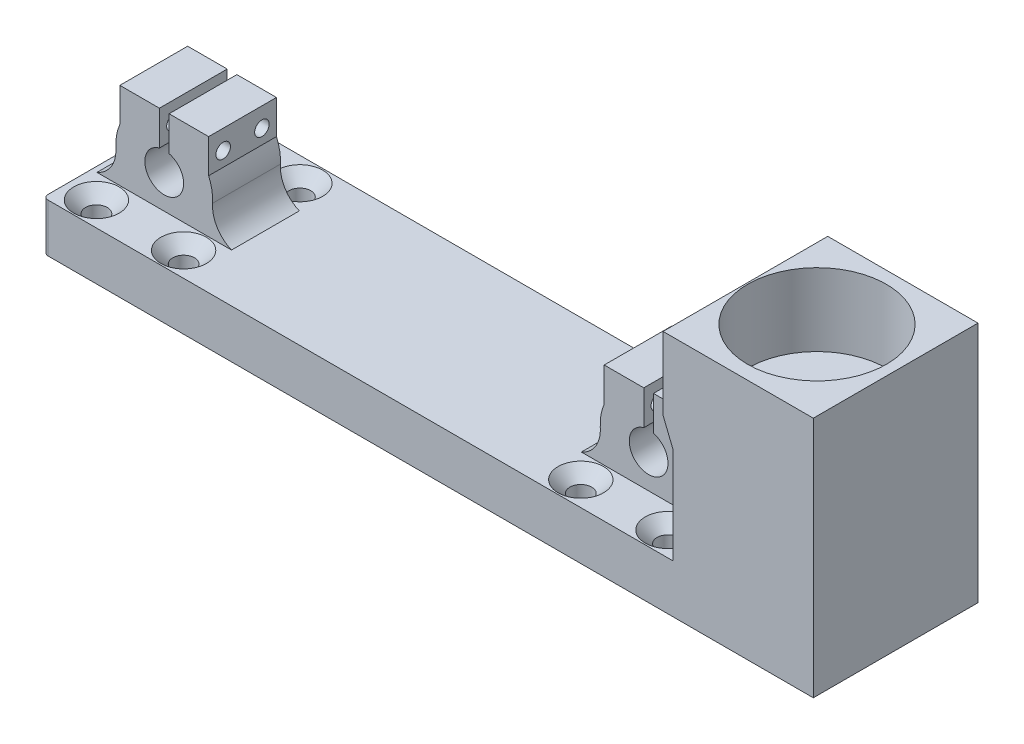
from build123d import *

# Parameters (mm, degrees)
SKETCH2_W                                       = 35
SKETCH2_H                                       = 34
SKETCH2_W_2                                     = 30
SKETCH2_R                                       = 2
BOSS_EXTRUDE1_DEPTH                             = 10
FILLET1_R                                       = 1
CSK_FOR_M4_FLAT_HEAD_MACHINE_SCREW1_D           = 4.5
CSK_FOR_M4_FLAT_HEAD_MACHINE_SCREW1_DEPTH       = 10
CSK_FOR_M4_FLAT_HEAD_MACHINE_SCREW1_CSINK_D     = 9.4
CSK_FOR_M4_FLAT_HEAD_MACHINE_SCREW1_CSINK_ANGLE = 90
SKETCH3_R                                       = 4
BOSS_EXTRUDE2_DEPTH                             = 14
F_3_0MM_DOWEL_HOLE1_D                           = 3
F_3_0MM_DOWEL_HOLE1_DEPTH                       = 18.33030278
CUT_EXTRUDE1_DEPTH                              = 25
CSK_FOR_M3_FLAT_HEAD_MACHINE_SCREW1_D           = 3.4
CSK_FOR_M3_FLAT_HEAD_MACHINE_SCREW1_DEPTH       = 10
CSK_FOR_M3_FLAT_HEAD_MACHINE_SCREW1_CSINK_D     = 6.3
CSK_FOR_M3_FLAT_HEAD_MACHINE_SCREW1_CSINK_ANGLE = 90
CSK_FOR_M3_FLAT_HEAD_MACHINE_SCREW1_TIP         = 1.021463052
SKETCH15_W                                      = 29
SKETCH15_H                                      = 34
BOSS_EXTRUDE3_DEPTH                             = 35
SKETCH16_R                                      = 14.325
BOSS_EXTRUDE4_DEPTH                             = 15
BOSS_EXTRUDE5_DEPTH                             = 34


with BuildPart() as part:
    # Sketch2 → Boss-Extrude1 (new body)
    with BuildSketch(Plane(origin=(0, 0, 0), x_dir=(1, 0, 0), z_dir=(0, 1, 0))):
        with Locations((23.5, -12)):
            Rectangle(SKETCH2_W, SKETCH2_H)
        with Locations((-9, -12)):
            Rectangle(SKETCH2_W_2, SKETCH2_H)
        with Locations((0, -24)):
            Circle(SKETCH2_R, mode=Mode.SUBTRACT)
        with Locations((-18, -24)):
            Circle(SKETCH2_R, mode=Mode.SUBTRACT)
        with Locations((-18, 0)):
            Circle(SKETCH2_R, mode=Mode.SUBTRACT)
        Circle(SKETCH2_R, mode=Mode.SUBTRACT)
    boss_extrude1 = extrude(amount=BOSS_EXTRUDE1_DEPTH)

    # Fillet1
    fillet1_edges = [part.edges().sort_by_distance(p)[0] for p in [
        (-24, 5, 29),
        (-24, 5, -5),
    ]]
    fillet(fillet1_edges, radius=FILLET1_R)

    # CSK for M4 Flat Head Machine Screw1
    with Locations(Plane(origin=(0, 10, 0), x_dir=(1, 0, 0), z_dir=(0, 1, 0))):
        with Locations((-18, 0), (0, 0), (0, -24), (-18, -24)):
            csk_for_m4_flat_head_machine_screw1 = CounterSinkHole(CSK_FOR_M4_FLAT_HEAD_MACHINE_SCREW1_D / 2, CSK_FOR_M4_FLAT_HEAD_MACHINE_SCREW1_CSINK_D / 2, depth=CSK_FOR_M4_FLAT_HEAD_MACHINE_SCREW1_DEPTH, counter_sink_angle=CSK_FOR_M4_FLAT_HEAD_MACHINE_SCREW1_CSINK_ANGLE)

    # Sketch3 → Boss-Extrude2 (add)
    with BuildSketch(Plane.XY.offset(19)):
        with BuildLine():
            ThreePointArc((-18.974091996, 16.203347698), (-19.957675635, 12.488863747), (-22.885197632, 10))
            Line((-22.885197632, 10), (4.885197632, 10))
            ThreePointArc((4.885197632, 10), (1.957675635, 12.488863747), (0.974091996, 16.203347698))
            ThreePointArc((0.974091996, 16.203347698), (0.979733938, 16.309510649), (0.987131717, 16.415565714))
            ThreePointArc((0.987131717, 16.415565714), (0.837737799, 18.716848177), (0.16515139, 20.922714683))
            Line((0.16515139, 20.922714683), (0.16515139, 27.923199435))
            Line((0.16515139, 27.923199435), (-18.16515139, 27.923199435))
            Line((-18.16515139, 27.923199435), (-18.16515139, 20.922714683))
            ThreePointArc((-18.16515139, 20.922714683), (-18.837737799, 18.716848177), (-18.987131717, 16.415565714))
            ThreePointArc((-18.987131717, 16.415565714), (-18.979733938, 16.309510649), (-18.974091996, 16.203347698))
        make_face()
        with Locations((-9, 16.922714683)):
            Circle(SKETCH3_R, mode=Mode.SUBTRACT)
    boss_extrude2 = extrude(amount=-BOSS_EXTRUDE2_DEPTH)

    # Ø3.0mm Dowel Hole1
    with Locations(Plane(origin=(0.16515139, 0, 0), x_dir=(0, 0, -1), z_dir=(1, 0, 0))):
        with Locations((-16, 23.923199435), (-8, 23.923199435)):
            f_3_0mm_dowel_hole1 = Hole(F_3_0MM_DOWEL_HOLE1_D / 2, depth=F_3_0MM_DOWEL_HOLE1_DEPTH)

    # Sketch10 → Cut-Extrude1 (cut, through all)
    with BuildSketch(Plane.XY.offset(19)):
        with BuildLine():
            Line((-9, 27.923199435), (-10, 27.923199435))
            Line((-10, 27.923199435), (-10, 20.795698029))
            ThreePointArc((-10, 20.795698029), (-9.50401717, 20.890833468), (-9, 20.922714683))
            Line((-9, 20.922714683), (-9, 27.923199435))
        make_face()
        with BuildLine():
            Line((-8, 27.923199435), (-9, 27.923199435))
            Line((-9, 27.923199435), (-9, 20.922714683))
            ThreePointArc((-9, 20.922714683), (-8.49598283, 20.890833468), (-8, 20.795698029))
            Line((-8, 20.795698029), (-8, 27.923199435))
        make_face()
    cut_extrude1 = extrude(amount=-CUT_EXTRUDE1_DEPTH, mode=Mode.SUBTRACT)

    # Mirror11: Boss-Extrude1, CSK for M4 Flat Head Machine Screw1, Boss-Extrude2, Ø3.0mm Dowel Hole1, Cut-Extrude1 across plane
    add(boss_extrude1.mirror(Plane(origin=(41, 10, 0), x_dir=(0, 0, 1), z_dir=(1, 0, 0))))
    add(csk_for_m4_flat_head_machine_screw1.mirror(Plane(origin=(41, 10, 0), x_dir=(0, 0, 1), z_dir=(1, 0, 0))), mode=Mode.SUBTRACT)
    add(boss_extrude2.mirror(Plane(origin=(41, 10, 0), x_dir=(0, 0, 1), z_dir=(1, 0, 0))))
    add(f_3_0mm_dowel_hole1.mirror(Plane(origin=(41, 10, 0), x_dir=(0, 0, 1), z_dir=(1, 0, 0))), mode=Mode.SUBTRACT)
    add(cut_extrude1.mirror(Plane(origin=(41, 10, 0), x_dir=(0, 0, 1), z_dir=(1, 0, 0))), mode=Mode.SUBTRACT)

    # CSK for M3 Flat Head Machine Screw1
    with Locations(Plane(origin=(0, 0, -5), x_dir=(-1, 0, 0), z_dir=(0, 0, -1))):
        with Locations((-69.114802368, 5), (-59.114802368, 5), (-13.885197632, 5), (-23.885197632, 5)):
            CounterSinkHole(CSK_FOR_M3_FLAT_HEAD_MACHINE_SCREW1_D / 2, CSK_FOR_M3_FLAT_HEAD_MACHINE_SCREW1_CSINK_D / 2, depth=CSK_FOR_M3_FLAT_HEAD_MACHINE_SCREW1_DEPTH, counter_sink_angle=CSK_FOR_M3_FLAT_HEAD_MACHINE_SCREW1_CSINK_ANGLE)
            with Locations((0, 0, -(CSK_FOR_M3_FLAT_HEAD_MACHINE_SCREW1_DEPTH + CSK_FOR_M3_FLAT_HEAD_MACHINE_SCREW1_TIP / 2))):  # 118° drill point
                Cone(0, CSK_FOR_M3_FLAT_HEAD_MACHINE_SCREW1_D / 2, CSK_FOR_M3_FLAT_HEAD_MACHINE_SCREW1_TIP, mode=Mode.SUBTRACT)

    # Sketch15 → Boss-Extrude3 (add)
    with BuildSketch(Plane(origin=(0, 0, 0), x_dir=(1, 0, 0), z_dir=(0, 1, 0))):
        with Locations((120.5, -12)):
            Rectangle(SKETCH15_W, SKETCH15_H)
    extrude(amount=BOSS_EXTRUDE3_DEPTH)

    # Sketch16 → Boss-Extrude4 (add)
    with BuildSketch(Plane(origin=(0, 35, 0), x_dir=(1, 0, 0), z_dir=(0, 1, 0))):
        Polygon((103.982508934, -29), (135, -29), (135, 5), (103.982508934, 5), (103.982508934, -11.839034668), align=None)
        with Locations((118.6, -11.839034668)):
            Circle(SKETCH16_R, mode=Mode.SUBTRACT)
    extrude(amount=BOSS_EXTRUDE4_DEPTH)

    # Sketch17 → Boss-Extrude5 (add)
    with BuildSketch(Plane.XY.offset(29)):
        Polygon((103.982508934, 35), (106, 30), (106, 35), align=None)
    extrude(amount=-BOSS_EXTRUDE5_DEPTH)


solid = part.part
